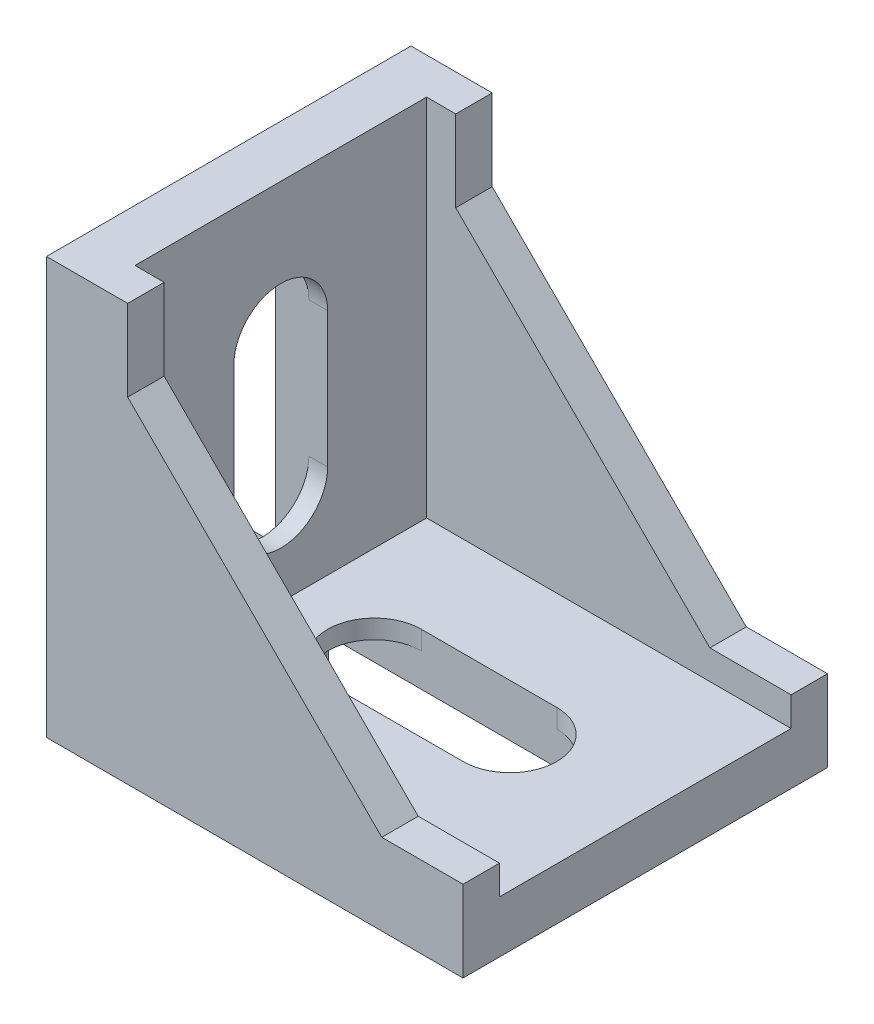
from build123d import *

# Parameters (mm, degrees)
EXTRUDE_1_DEPTH      = 17.5
EXTRUDE_1_DEPTH_BACK = 17.5
SKETCH_2_W           = 35
SKETCH_2_H           = 28
CUT_EXTRUDE_1_DEPTH  = 35
CUT_EXTRUDE_2_DEPTH  = 6
CUT_EXTRUDE_3_DEPTH  = 6
SKETCH_5_W           = 9
SKETCH_5_H           = 28
SKETCH_5_W_2         = 5.8
SKETCH_5_H_2         = 35
CUT_EXTRUDE_4_DEPTH  = 3.2
SKETCH_6_W           = 28
SKETCH_6_H           = 9
SKETCH_6_W_2         = 35
SKETCH_6_H_2         = 6
CUT_EXTRUDE_5_DEPTH  = 3.2
SKETCH_8_W           = 2
SKETCH_8_H           = 2
EXTRUDE_2_DEPTH      = 3.9
EXTRUDE_2_DEPTH_BACK = 3.9
FILLET_2_R           = 0.5


with BuildPart() as part:
    # Sketch 1 → Extrude 1 (new body, two sides)
    with BuildSketch(Plane.XY) as extrude_1_sk:
        Polygon((0, 0), (0, 40), (7.8, 40), (7.8, 32.2), (32.2, 7.8), (40, 7.8), (40, 0), align=None)
    extrude(amount=EXTRUDE_1_DEPTH)
    extrude(extrude_1_sk.sketch, amount=-EXTRUDE_1_DEPTH_BACK)

    # Sketch 2 → Cut-Extrude 1 (cut)
    with BuildSketch(Plane(origin=(0, 40, 0), x_dir=(1, 0, 0), z_dir=(0, 1, 0))):
        with Locations((22.5, 0)):
            Rectangle(SKETCH_2_W, SKETCH_2_H)
    extrude(amount=-CUT_EXTRUDE_1_DEPTH, mode=Mode.SUBTRACT)

    # Sketch 3 → Cut-Extrude 2 (cut, through all)
    with BuildSketch(Plane(origin=(0, 5, 0), x_dir=(1, 0, 0), z_dir=(0, 1, 0))):
        with BuildLine():
            Line((14, 4.5), (27, 4.5))
            ThreePointArc((27, 4.5), (31.5, 0), (27, -4.5))
            Line((27, -4.5), (14, -4.5))
            ThreePointArc((14, -4.5), (9.5, 0), (14, 4.5))
        make_face()
    extrude(amount=-CUT_EXTRUDE_2_DEPTH, mode=Mode.SUBTRACT)

    # Sketch 4 → Cut-Extrude 3 (cut, through all)
    with BuildSketch(Plane(origin=(5, 0, 0), x_dir=(0, 0, -1), z_dir=(1, 0, 0))):
        with BuildLine():
            Line((4.5, 27), (4.5, 14))
            ThreePointArc((4.5, 14), (0, 9.5), (-4.5, 14))
            Line((-4.5, 14), (-4.5, 27))
            ThreePointArc((-4.5, 27), (0, 31.5), (4.5, 27))
        make_face()
    extrude(amount=-CUT_EXTRUDE_3_DEPTH, mode=Mode.SUBTRACT)

    # Sketch 5 → Cut-Extrude 4 (cut)
    with BuildSketch(Plane.ZY):
        with Locations((0, 20)):
            Rectangle(SKETCH_5_W, SKETCH_5_H)
        with Locations((-11.6, 19.5)):
            Rectangle(SKETCH_5_W_2, SKETCH_5_H_2)
        with Locations((11.6, 19.5)):
            Rectangle(SKETCH_5_W_2, SKETCH_5_H_2)
    extrude(amount=-CUT_EXTRUDE_4_DEPTH, mode=Mode.SUBTRACT)

    # Sketch 6 → Cut-Extrude 5 (cut)
    with BuildSketch(Plane.XZ):
        with Locations((20, 0)):
            Rectangle(SKETCH_6_W, SKETCH_6_H)
        with Locations((20.5, 11)):
            Rectangle(SKETCH_6_W_2, SKETCH_6_H_2)
        with Locations((20.5, -11)):
            Rectangle(SKETCH_6_W_2, SKETCH_6_H_2)
    extrude(amount=-CUT_EXTRUDE_5_DEPTH, mode=Mode.SUBTRACT)

    # Sketch 8 → Extrude 2 (add, two sides)
    with BuildSketch(Plane.XY) as extrude_2_sk:
        with Locations((-1, 35)):
            Rectangle(SKETCH_8_W, SKETCH_8_H)
        with Locations((-1, 5)):
            Rectangle(SKETCH_8_W, SKETCH_8_H)
        with Locations((5, -1)):
            Rectangle(SKETCH_8_W, SKETCH_8_H)
        with Locations((35, -1)):
            Rectangle(SKETCH_8_W, SKETCH_8_H)
    extrude(amount=EXTRUDE_2_DEPTH)
    extrude(extrude_2_sk.sketch, amount=-EXTRUDE_2_DEPTH_BACK)

    # Fillet 2
    fillet_2_edges = [part.edges().sort_by_distance(p)[0] for p in [
        (-1, 34, -3.9),
        (-1, 36, -3.9),
        (-1, 36, 3.9),
        (-1, 34, 3.9),
        (-1, 6, -3.9),
        (-1, 4, -3.9),
        (-1, 6, 3.9),
        (-1, 4, 3.9),
        (6, -1, -3.9),
        (4, -1, -3.9),
        (4, -1, 3.9),
        (6, -1, 3.9),
        (36, -1, -3.9),
        (34, -1, -3.9),
        (34, -1, 3.9),
        (36, -1, 3.9),
    ]]
    fillet(fillet_2_edges, radius=FILLET_2_R)


solid = part.part
